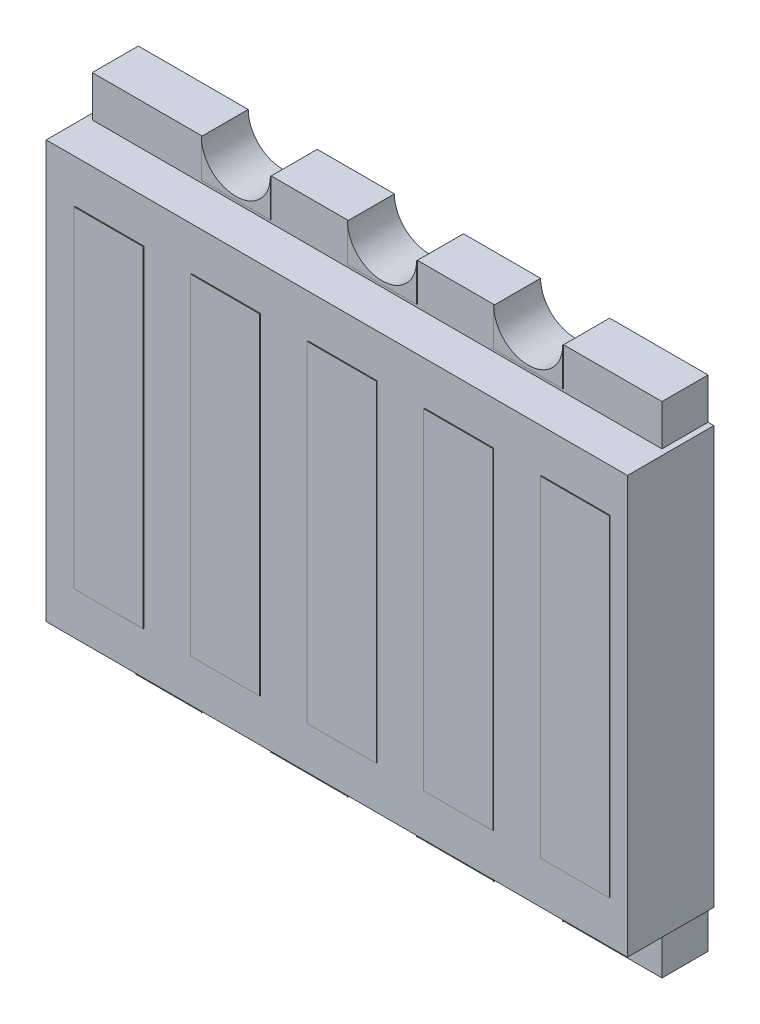
from build123d import *

# Parameters (mm, degrees)
SKETCH1_W             = 19.8
SKETCH1_H             = 17.35
BOSS_EXTRUDE1_DEPTH   = 1.6
CUT_EXTRUDE2_START    = -1.6
CUT_EXTRUDE2_DEPTH    = 4.2
BOSS_EXTRUDE2_DEPTH   = 3
CUT_EXTRUDE3_DEPTH    = 3
BOSS_EXTRUDE7_DEPTH   = 0.03
BOSS_EXTRUDE7_2_DEPTH = 0.03
BOSS_EXTRUDE7_3_DEPTH = 0.03
SKETCH8_W             = 2.4
SKETCH8_H             = 11.5
BOSS_EXTRUDE8_DEPTH   = 3.03
LPATTERN1_COUNT       = 3
LPATTERN1_PITCH       = 4.05
LPATTERN1_COL_COUNT   = 3
LPATTERN1_COL_PITCH   = 4.05


with BuildPart() as part:
    # Sketch1 → Boss-Extrude1 (new body)
    with BuildSketch(Plane.XY):
        with Locations((9.9, 8.675)):
            Rectangle(SKETCH1_W, SKETCH1_H)
    extrude(amount=BOSS_EXTRUDE1_DEPTH)

    # Sketch3 → Cut-Extrude2 (cut)
    with BuildSketch(Plane.XY.offset(CUT_EXTRUDE2_START)):
        with BuildLine():
            ThreePointArc((8.9, 0), (10.1, 1.2), (11.3, 0))
            Line((11.3, 0), (9.9, 0))
            Line((9.9, 0), (8.9, 0))
        make_face()
        with BuildLine():
            ThreePointArc((13.98, 0), (15.18, 1.2), (16.38, 0))
            Line((16.38, 0), (15.18, 0))
            Line((15.18, 0), (13.98, 0))
        make_face()
        with BuildLine():
            ThreePointArc((3.82, 0), (5.02, 1.2), (6.22, 0))
            Line((6.22, 0), (5.02, 0))
            Line((5.02, 0), (3.82, 0))
        make_face()
    cut_extrude2 = extrude(amount=CUT_EXTRUDE2_DEPTH, mode=Mode.SUBTRACT)

    # Mirror1: Cut-Extrude2 across plane
    add(cut_extrude2.mirror(Plane.ZX.offset(8.675)), mode=Mode.SUBTRACT)

    # Sketch4 → Boss-Extrude2 (add)
    with BuildSketch(Plane.XY):
        Polygon((-0.2, 1.425), (19.8, 1.425), (20, 1.425), (20, 15.925), (0, 15.925), (-0.2, 15.925), align=None)
    extrude(amount=BOSS_EXTRUDE2_DEPTH)

    # Sketch6 → Cut-Extrude3 (cut)
    with BuildSketch(Plane.XY.offset(3)):
        Polygon((1.522230631, 0), (0.097230631, 1.425), (0, 1.425), (0, 0), align=None)
    extrude(amount=-CUT_EXTRUDE3_DEPTH, mode=Mode.SUBTRACT)


with BuildPart() as body_2:
    # Sketch7 → Boss-Extrude7 (new body)
    with BuildSketch(Plane.XY.offset(1.6)):
        with BuildLine():
            Line((3.82, 1.3125), (3.82, 0))
            ThreePointArc((3.82, 0), (5.02, 1.2), (6.22, 0))
            Line((6.22, 0), (6.22, 1.3125))
            Line((6.22, 1.3125), (3.82, 1.3125))
        make_face()
    boss_extrude7 = extrude(amount=BOSS_EXTRUDE7_DEPTH)


with BuildPart() as body_3:
    # Sketch7 → Boss-Extrude7 2 (new body)
    with BuildSketch(Plane.XY.offset(1.6)):
        with BuildLine():
            Line((8.9, 1.3125), (8.9, 0))
            ThreePointArc((8.9, 0), (10.1, 1.2), (11.3, 0))
            Line((11.3, 0), (11.3, 1.3125))
            Line((11.3, 1.3125), (8.9, 1.3125))
        make_face()
    boss_extrude7_2 = extrude(amount=BOSS_EXTRUDE7_2_DEPTH)


with BuildPart() as body_4:
    # Sketch7 → Boss-Extrude7 3 (new body)
    with BuildSketch(Plane.XY.offset(1.6)):
        with BuildLine():
            Line((13.98, 1.3125), (13.98, 0))
            ThreePointArc((13.98, 0), (15.18, 1.2), (16.38, 0))
            Line((16.38, 0), (16.38, 1.3125))
            Line((16.38, 1.3125), (13.98, 1.3125))
        make_face()
    boss_extrude7_3 = extrude(amount=BOSS_EXTRUDE7_3_DEPTH)


with BuildPart() as part_1:
    add(part.part)

    # Mirror2: Boss-Extrude7, Boss-Extrude7 2, Boss-Extrude7 3 across plane
    add(boss_extrude7.mirror(Plane.ZX.offset(8.675)))
    add(boss_extrude7_2.mirror(Plane.ZX.offset(8.675)))
    add(boss_extrude7_3.mirror(Plane.ZX.offset(8.675)))

    # Sketch8 → Boss-Extrude8 (add)
    with BuildSketch(Plane.XY):
        with Locations((10.1, 8.675)):
            Rectangle(SKETCH8_W, SKETCH8_H)
    boss_extrude8 = extrude(amount=BOSS_EXTRUDE8_DEPTH)

    # LPattern1: Boss-Extrude8 ×3
    with Locations(*[(i * LPATTERN1_PITCH, 0, 0) for i in range(1, LPATTERN1_COUNT)]):
        add(boss_extrude8)

    # LPattern1 col: Boss-Extrude8 ×3
    with Locations(*[(-i * LPATTERN1_COL_PITCH, 0, 0) for i in range(1, LPATTERN1_COL_COUNT)]):
        add(boss_extrude8)


solid = Compound([body_2.part, body_3.part, body_4.part, part_1.part])
